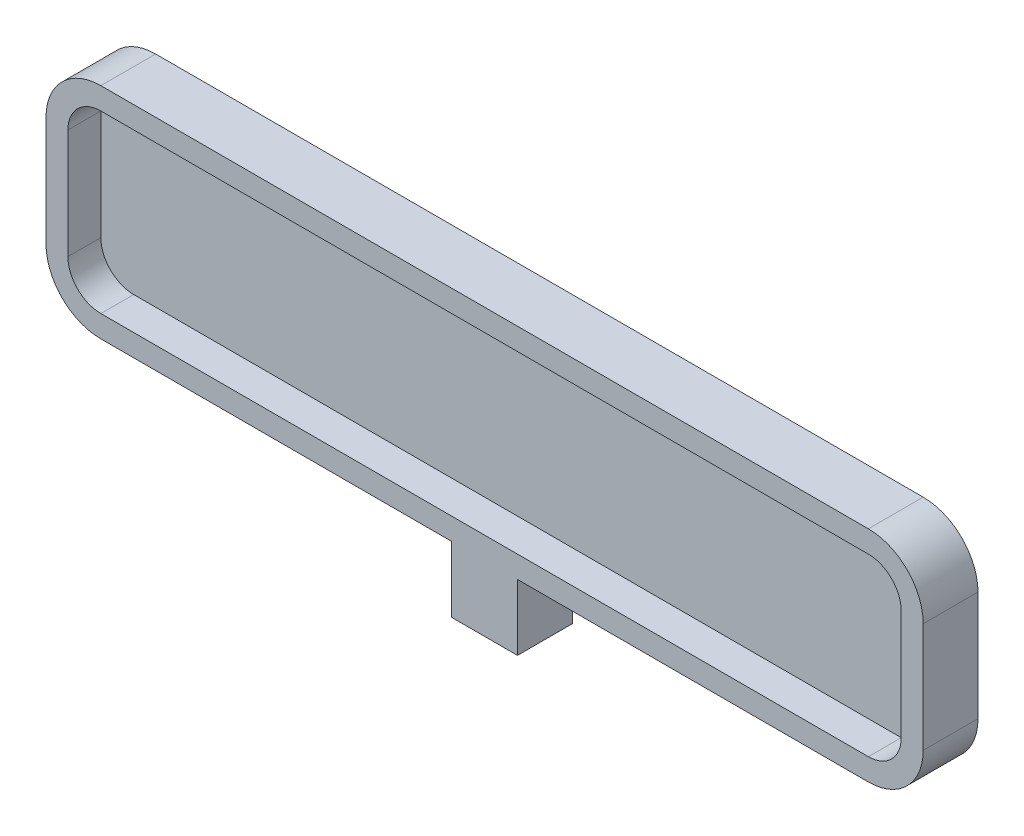
from build123d import *

# Parameters (mm, degrees)
SKETCH1_W           = 80
SKETCH1_H           = 20
BOSS_EXTRUDE1_DEPTH = 5
FILLET1_R           = 5
SHELL1_T            = -2
SKETCH3_W           = 6
SKETCH3_H           = 5
BOSS_EXTRUDE2_DEPTH = 6
SKETCH4_R           = 2
CUT_EXTRUDE1_DEPTH  = 4


with BuildPart() as part:
    # Sketch1 → Boss-Extrude1 (new body)
    with BuildSketch(Plane.XY):
        Rectangle(SKETCH1_W, SKETCH1_H)
    extrude(amount=BOSS_EXTRUDE1_DEPTH)

    # Fillet1
    fillet1_edges = [part.edges().sort_by_distance(p)[0] for p in [
        (-40, 10, 2.5),
        (40, 10, 2.5),
        (40, -10, 2.5),
        (-40, -10, 2.5),
    ]]
    fillet(fillet1_edges, radius=FILLET1_R)

    # Shell1
    shell1_openings = [part.faces().sort_by_distance(p)[0] for p in [
        (0, 0, 5),
    ]]
    offset(amount=SHELL1_T, openings=shell1_openings, kind=Kind.INTERSECTION)

    # Sketch3 → Boss-Extrude2 (add)
    with BuildSketch(Plane.XZ.offset(10)):
        with Locations((0, 2.5)):
            Rectangle(SKETCH3_W, SKETCH3_H)
    extrude(amount=BOSS_EXTRUDE2_DEPTH)

    # Sketch4 → Cut-Extrude1 (cut)
    with BuildSketch(Plane.XZ.offset(16)):
        with Locations((0, 2.5)):
            Circle(SKETCH4_R)
    extrude(amount=-CUT_EXTRUDE1_DEPTH, mode=Mode.SUBTRACT)


solid = part.part
